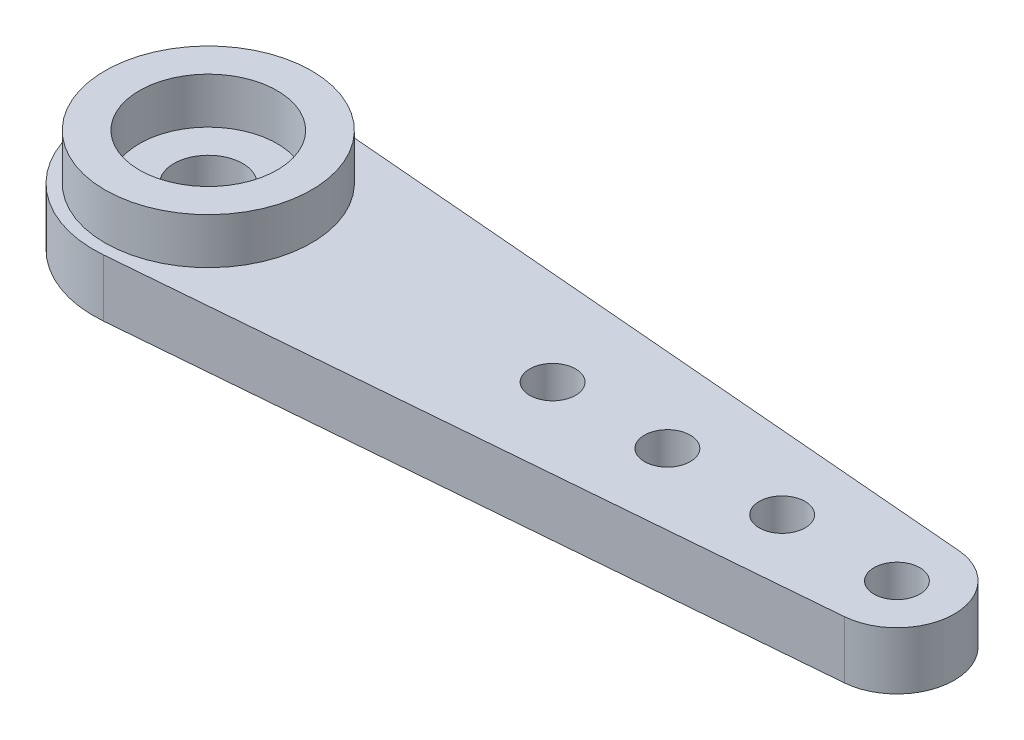
from build123d import *

# Parameters (mm, degrees)
SKETCH1_R           = 1
BOSS_EXTRUDE1_DEPTH = 2.5
SKETCH2_R           = 4.5
SKETCH2_R_2         = 3
BOSS_EXTRUDE2_DEPTH = 2
SKETCH3_R           = 1.5
CUT_EXTRUDE1_DEPTH  = 3.5
SKETCH4_R           = 3.5
CUT_EXTRUDE2_DEPTH  = 0.2


with BuildPart() as part:
    # Sketch1 → Boss-Extrude1 (new body)
    with BuildSketch(Plane(origin=(0, 0, 0), x_dir=(1, 0, 0), z_dir=(0, 1, 0))):
        with BuildLine():
            Line((0.208333333, 2.491304321), (-29.583333333, 4.982608643))
            ThreePointArc((-29.583333333, 4.982608643), (-35, 0), (-29.583333333, -4.982608643))
            Line((-29.583333333, -4.982608643), (0.208333333, -2.491304321))
            ThreePointArc((0.208333333, -2.491304321), (2.5, 0), (0.208333333, 2.491304321))
        make_face()
        with Locations((-15, 0)):
            Circle(SKETCH1_R, mode=Mode.SUBTRACT)
        with Locations((-10, 0)):
            Circle(SKETCH1_R, mode=Mode.SUBTRACT)
        with Locations((-5, 0)):
            Circle(SKETCH1_R, mode=Mode.SUBTRACT)
        Circle(SKETCH1_R, mode=Mode.SUBTRACT)
    extrude(amount=BOSS_EXTRUDE1_DEPTH)

    # Sketch2 → Boss-Extrude2 (add)
    with BuildSketch(Plane(origin=(0, 2.5, 0), x_dir=(1, 0, 0), z_dir=(0, 1, 0))):
        with Locations((-30, 0)):
            Circle(SKETCH2_R)
        with Locations((-30, 0)):
            Circle(SKETCH2_R_2, mode=Mode.SUBTRACT)
    extrude(amount=BOSS_EXTRUDE2_DEPTH)

    # Sketch3 → Cut-Extrude1 (cut, through all)
    with BuildSketch(Plane(origin=(0, 2.5, 0), x_dir=(1, 0, 0), z_dir=(0, 1, 0))):
        with Locations((-30, 0)):
            Circle(SKETCH3_R)
    extrude(amount=-CUT_EXTRUDE1_DEPTH, mode=Mode.SUBTRACT)

    # Sketch4 → Cut-Extrude2 (cut)
    with BuildSketch(Plane.XZ):
        with Locations((-30, 0)):
            Circle(SKETCH4_R)
    extrude(amount=-CUT_EXTRUDE2_DEPTH, mode=Mode.SUBTRACT)


solid = part.part
